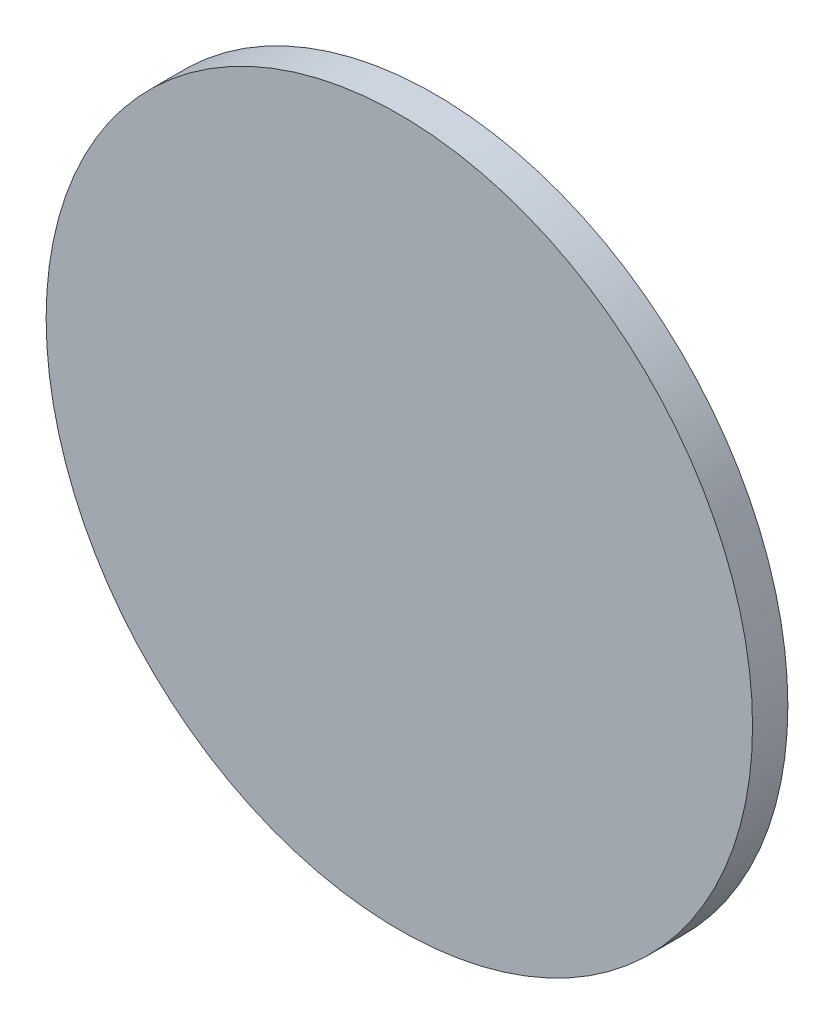
from build123d import *

# Parameters (mm, degrees)
SKETCH1_R           = 200
BOSS_EXTRUDE1_DEPTH = 20


with BuildPart() as part:
    # Sketch1 → Boss-Extrude1 (new body)
    with BuildSketch(Plane.XY):
        Circle(SKETCH1_R)
    extrude(amount=BOSS_EXTRUDE1_DEPTH)


solid = part.part
